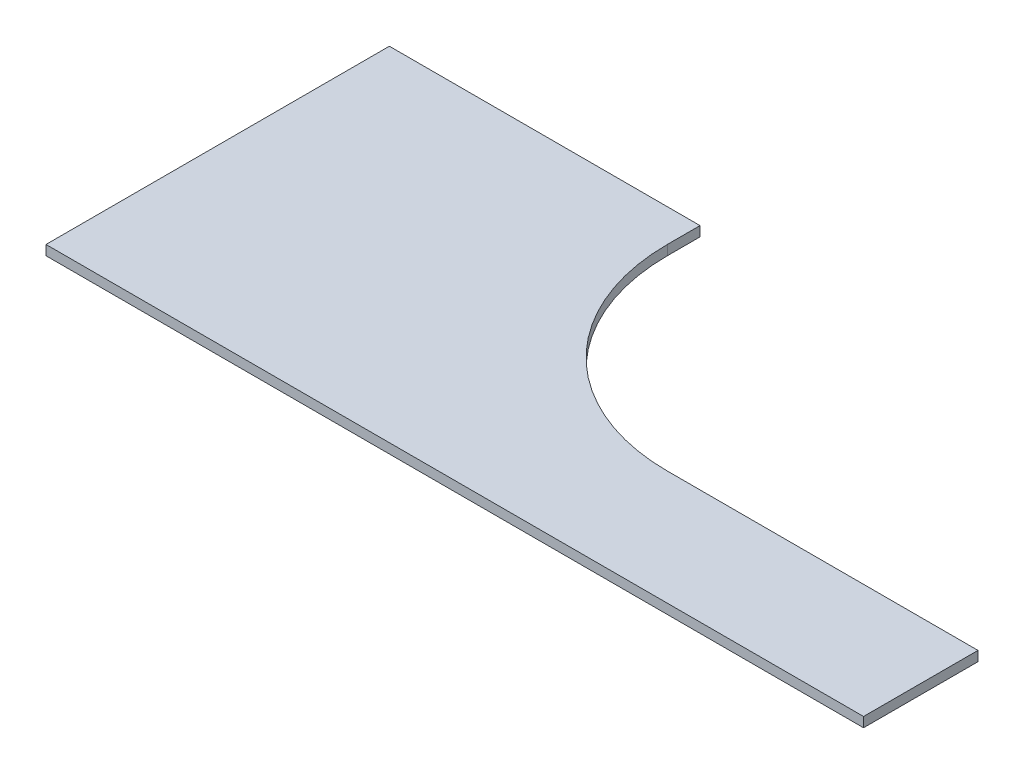
from build123d import *

# Parameters (mm, degrees)
BOSS_EXTRUDE1_DEPTH = 6
SCALE1_SCALE        = 0.75


with BuildPart() as part:
    # Sketch1 → Boss-Extrude1 (new body)
    with BuildSketch(Plane(origin=(0, 0, 0), x_dir=(1, 0, 0), z_dir=(0, 1, 0))):
        with BuildLine():
            Line((-10, 70), (-10, 90))
            Line((-10, 90), (-200, 90))
            Line((-200, 90), (-200, -120))
            Line((-200, -120), (300, -120))
            Line((300, -120), (300, -50))
            Line((300, -50), (110, -50))
            ThreePointArc((110, -50), (25.147186258, -14.852813742), (-10, 70))
        make_face()
    extrude(amount=-BOSS_EXTRUDE1_DEPTH)


with BuildPart() as part_1:
    # Scale1: scaled about (-15.320244378, -3, 38.872638603)
    add(part.part.scale(SCALE1_SCALE).moved(Location((-3.830061094, -0.75, 9.718159651))))


solid = part_1.part
